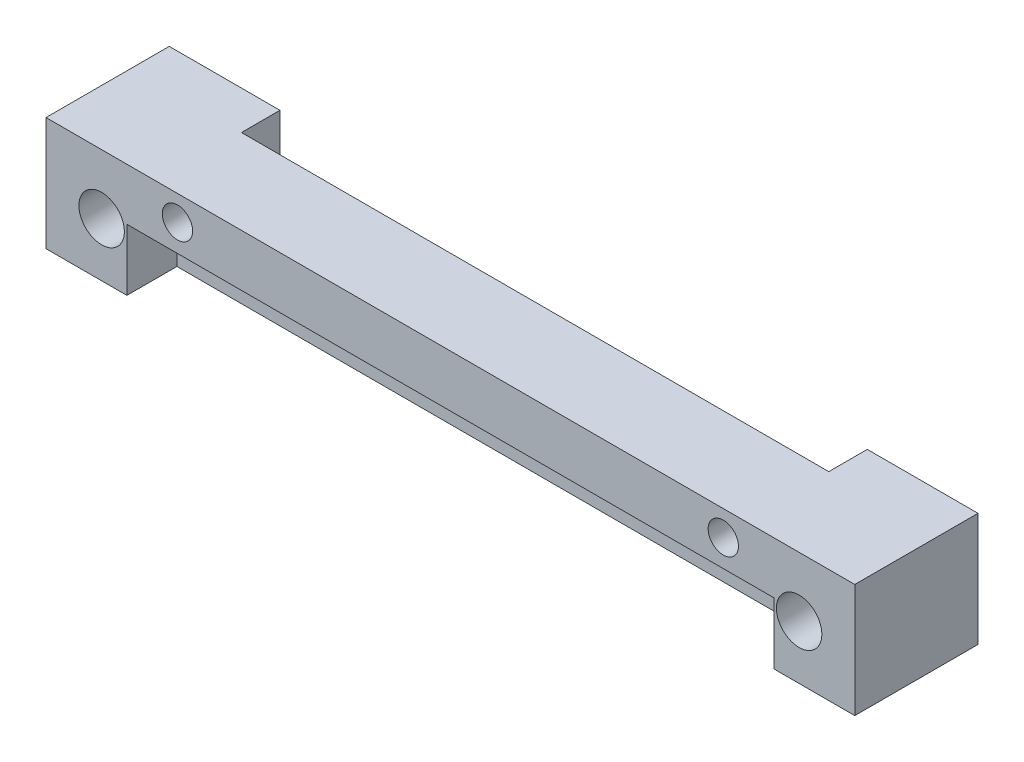
from build123d import *

# Parameters (mm, degrees)
SKETCH1_W                                   = 53.34
SKETCH1_H                                   = 8.89
F_16X19MM_BAR_SAWN_IN_HALF_WIDTH_WISE_DEPTH = 15.4686
SKETCH2_W                                   = 53.34
SKETCH2_H                                   = 15.4686
CUT_EXTRUDE1_DEPTH                          = 0.762
SKETCH4_W                                   = 53.34
SKETCH4_H                                   = 8.128
CUT_EXTRUDE2_DEPTH                          = 7.9756
SKETCH5_W                                   = 3.302
SKETCH5_H                                   = 4.064
CUT_EXTRUDE3_DEPTH                          = 21.336
CUT_EXTRUDE3_DEPTH_BACK                     = 21.336
M3_CLEARANCE_REACH                          = 10.128
SKETCH6_R                                   = 1.4986
SKETCH7_R                                   = 1
TAPPED_M2_DEPTH                             = 4.683
TAPPED_M2_DEPTH_BACK                        = 5.445
SKETCH10_W                                  = 38.735
SKETCH10_H                                  = 7.493
CUT_EXTRUDE6_DEPTH                          = 2.54


with BuildPart() as part:
    # Sketch1 → 16x19mm bar sawn in half width wise (new body)
    with BuildSketch(Plane(origin=(0, 0.508, 0), x_dir=(1, 0, 0), z_dir=(0, 1, 0))):
        Rectangle(SKETCH1_W, SKETCH1_H)
    extrude(amount=F_16X19MM_BAR_SAWN_IN_HALF_WIDTH_WISE_DEPTH)

    # Sketch2 → Cut-Extrude1 (cut)
    with BuildSketch(Plane.XY.offset(4.445)):
        with Locations((0, 8.2423)):
            Rectangle(SKETCH2_W, SKETCH2_H)
    extrude(amount=-CUT_EXTRUDE1_DEPTH, mode=Mode.SUBTRACT)

    # Sketch4 → Cut-Extrude2 (cut)
    with BuildSketch(Plane(origin=(0, 15.9766, 0), x_dir=(1, 0, 0), z_dir=(0, 1, 0))):
        with Locations((0, 0.381)):
            Rectangle(SKETCH4_W, SKETCH4_H)
    extrude(amount=-CUT_EXTRUDE2_DEPTH, mode=Mode.SUBTRACT)

    # Sketch5 → Cut-Extrude3 (cut, two sides)
    with BuildSketch(Plane(origin=(0, 0, 0), x_dir=(0, 0, -1), z_dir=(1, 0, 0))) as cut_extrude3_sk:
        with Locations((-2.032, 2.54)):
            Rectangle(SKETCH5_W, SKETCH5_H)
    extrude(amount=CUT_EXTRUDE3_DEPTH, mode=Mode.SUBTRACT)
    extrude(cut_extrude3_sk.sketch, amount=-CUT_EXTRUDE3_DEPTH_BACK, mode=Mode.SUBTRACT)

    # Sketch6 → M3 Clearance (cut, up to next)
    with BuildSketch(Plane(origin=(0, 0, -4.445), x_dir=(-1, 0, 0), z_dir=(0, 0, -1)), mode=Mode.PRIVATE) as m3_clearance_sk1:
        with Locations((23, 4.064)):
            Circle(SKETCH6_R)
    m3_clearance_tool1 = extrude(m3_clearance_sk1.sketch, amount=-M3_CLEARANCE_REACH, mode=Mode.PRIVATE) & part.part
    add(m3_clearance_tool1.solids().sort_by_distance((-23, 4.064, -4.445))[0], mode=Mode.SUBTRACT)
    # Sketch6 → M3 Clearance (cut, up to next)
    with BuildSketch(Plane(origin=(0, 0, -4.445), x_dir=(-1, 0, 0), z_dir=(0, 0, -1)), mode=Mode.PRIVATE) as m3_clearance_sk2:
        with Locations((-23, 4.064)):
            Circle(SKETCH6_R)
    m3_clearance_tool2 = extrude(m3_clearance_sk2.sketch, amount=-M3_CLEARANCE_REACH, mode=Mode.PRIVATE) & part.part
    add(m3_clearance_tool2.solids().sort_by_distance((23, 4.064, -4.445))[0], mode=Mode.SUBTRACT)

    # Sketch7 → Tapped M2 (cut, two sides)
    with BuildSketch(Plane.XY) as tapped_m2_sk:
        with Locations((18, 6.343629359)):
            Circle(SKETCH7_R)
        with Locations((-18, 6.343629359)):
            Circle(SKETCH7_R)
    extrude(amount=TAPPED_M2_DEPTH, mode=Mode.SUBTRACT)
    extrude(tapped_m2_sk.sketch, amount=-TAPPED_M2_DEPTH_BACK, mode=Mode.SUBTRACT)

    # Sketch10 → Cut-Extrude6 (cut)
    with BuildSketch(Plane(origin=(0, 0, -4.445), x_dir=(-1, 0, 0), z_dir=(0, 0, -1))):
        with Locations((0, 4.2545)):
            Rectangle(SKETCH10_W, SKETCH10_H)
    extrude(amount=-CUT_EXTRUDE6_DEPTH, mode=Mode.SUBTRACT)


solid = part.part
